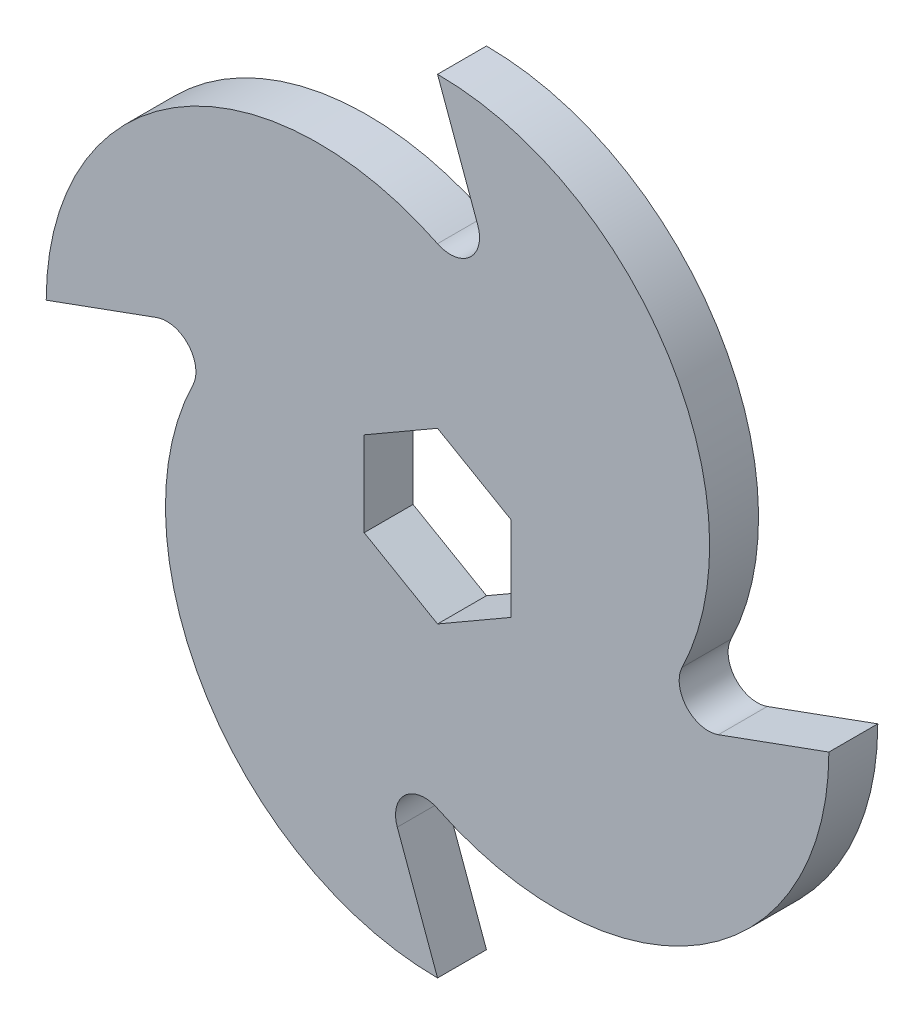
from build123d import *

# Parameters (mm, degrees)
BOSS_EXTRUDE1_DEPTH = 3.175


with BuildPart() as part:
    # Sketch2 → Boss-Extrude1 (new body, symmetric)
    with BuildSketch(Plane.XY):
        with BuildLine():
            ThreePointArc((-5.221965604, -36.452767418), (-4.196850428, -32.340432027), (0, -31.75))
            ThreePointArc((0, -31.75), (34.198681309, -29.952890094), (50.8, 0))
            Line((50.8, 0), (36.452767418, -5.221965604))
            ThreePointArc((36.452767418, -5.221965604), (32.340432027, -4.196850428), (31.75, 0))
            ThreePointArc((31.75, 0), (29.952890094, 34.198681309), (0, 50.8))
            Line((0, 50.8), (5.221965604, 36.452767418))
            ThreePointArc((5.221965604, 36.452767418), (4.196850428, 32.340432027), (0, 31.75))
            ThreePointArc((0, 31.75), (-34.198681309, 29.952890094), (-50.8, 0))
            Line((-50.8, 0), (-36.452767418, 5.221965604))
            ThreePointArc((-36.452767418, 5.221965604), (-32.340432027, 4.196850428), (-31.75, 0))
            ThreePointArc((-31.75, 0), (-29.952890094, -34.198681309), (0, -50.8))
            Line((0, -50.8), (-5.221965604, -36.452767418))
        make_face()
        Polygon((9.525, -5.499261314), (0, -10.998522628), (-9.525, -5.499261314), (-9.525, 5.499261314), (0, 10.998522628), (9.525, 5.499261314), align=None, mode=Mode.SUBTRACT)
    extrude(amount=BOSS_EXTRUDE1_DEPTH, both=True)


solid = part.part
